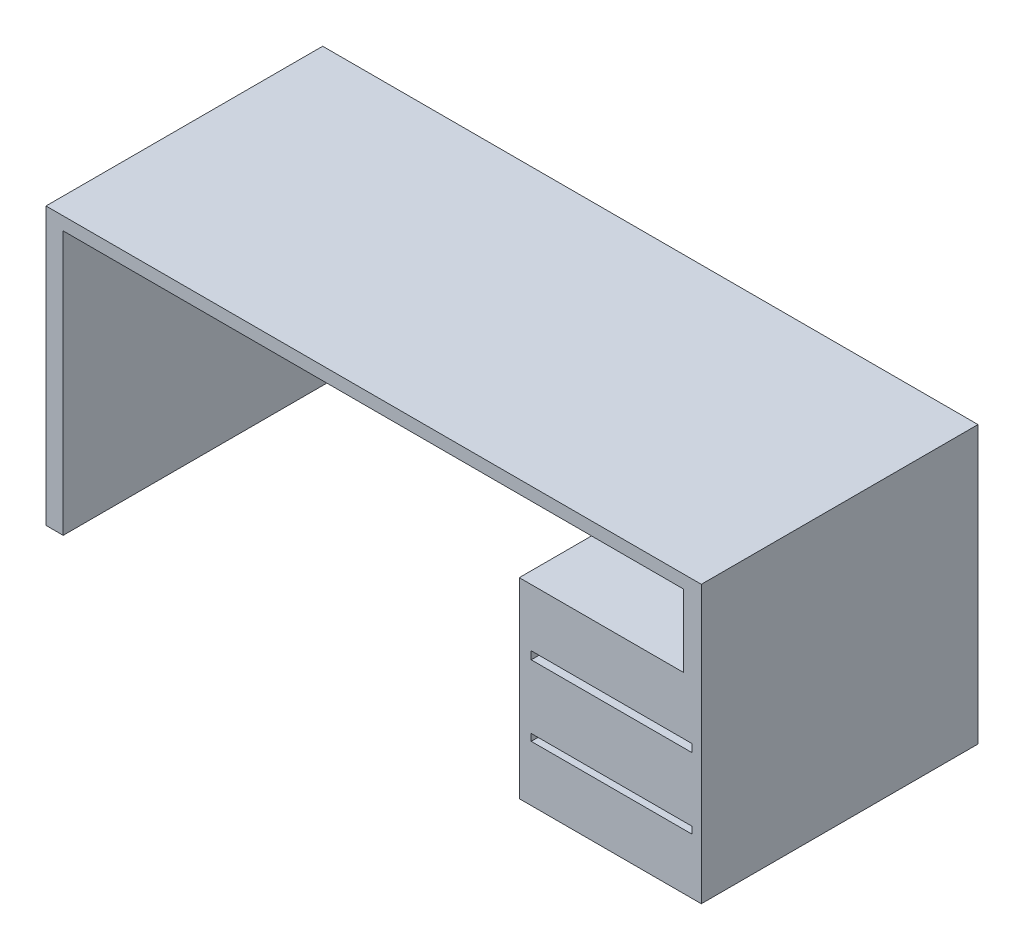
from build123d import *

# Parameters (mm, degrees)
SALIENTE_EXTRUIR1_DEPTH = 760
CROQUIS3_W              = 441.770557025
CROQUIS3_H              = 21.549783269
CROQUIS3_H_2            = 18.85606036
CORTAR_EXTRUIR1_DEPTH   = 899


with BuildPart() as part:
    # Croquis2 → Saliente-Extruir1 (new body)
    with BuildSketch(Plane.XY):
        Polygon((0, 0), (0, 760), (1800, 760), (1800, 0), (1300, 0), (1300, 525.845869983), (1750.467945366, 525.845869983), (1750.467945366, 724.319370664), (47.213684499, 724.319370664), (47.213684499, 0), align=None)
    extrude(amount=SALIENTE_EXTRUIR1_DEPTH)

    # Croquis3 → Cortar-Extruir1 (cut)
    with BuildSketch(Plane.XY.offset(760)):
        with Locations((1553.640740137, 357.52664055)):
            Rectangle(CROQUIS3_W, CROQUIS3_H)
        with Locations((1553.640740137, 162.23172967)):
            Rectangle(CROQUIS3_W, CROQUIS3_H_2)
    extrude(amount=-CORTAR_EXTRUIR1_DEPTH, mode=Mode.SUBTRACT)


solid = part.part
